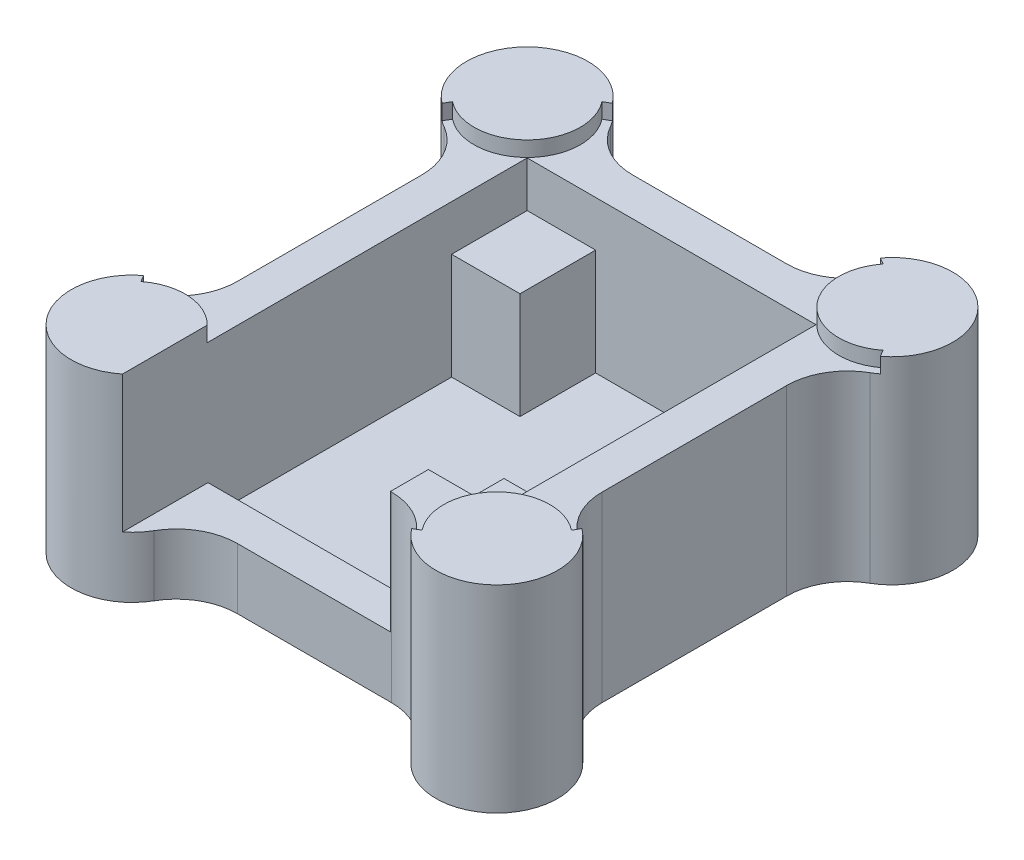
from build123d import *

# Parameters (mm, degrees)
BOSS_EXTRUDE1_DEPTH     = 12
CUT_EXTRUDE1_DEPTH      = 10
FILLET1_R               = 4
BOSS_EXTRUDE3_DEPTH     = 1
MIRROR2_COPY_1_DEPTH    = 1
SKETCH3_W               = 14.5
SKETCH3_H               = 5.622498999
CUT_EXTRUDE2_DEPTH      = 2
CUT_EXTRUDE2_DEPTH_BACK = 8
SKETCH4_W               = 4.5
SKETCH4_H               = 4.973684211
CUT_EXTRUDE3_DEPTH      = 3


with BuildPart() as part:
    # Sketch1 → Boss-Extrude1 (new body)
    with BuildSketch(Plane(origin=(0, 0, 0), x_dir=(1, 0, 0), z_dir=(0, 1, 0))):
        with BuildLine():
            Line((-8, -13), (8, -13))
            ThreePointArc((8, -13), (14.828427125, -15.828427125), (12, -9))
            Line((12, -9), (12, 9))
            ThreePointArc((12, 9), (14.828427125, 15.828427125), (8, 13))
            Line((8, 13), (-8, 13))
            ThreePointArc((-8, 13), (-14.828427125, 15.828427125), (-12, 9))
            Line((-12, 9), (-12, -9))
            ThreePointArc((-12, -9), (-14.828427125, -15.828427125), (-8, -13))
        make_face()
    extrude(amount=BOSS_EXTRUDE1_DEPTH)

    # Sketch2 → Cut-Extrude1 (cut)
    with BuildSketch(Plane(origin=(0, 12, 0), x_dir=(1, 0, 0), z_dir=(0, 1, 0))):
        Polygon((-9.5, -10.5), (5, -10.5), (5, -5.526315789), (9.5, -5.526315789), (9.5, 10.5), (-5, 10.5), (-5, 5.526315789), (-9.5, 5.526315789), align=None)
    extrude(amount=-CUT_EXTRUDE1_DEPTH, mode=Mode.SUBTRACT)

    # Fillet1
    fillet1_edges = [part.edges().sort_by_distance(p)[0] for p in [
        (12, 6, -9),
        (12, 6, 9),
        (8, 6, 13),
        (-8, 6, 13),
        (-12, 6, 9),
        (-12, 6, -9),
        (-8, 6, -13),
        (8, 6, -13),
    ]]
    fillet(fillet1_edges, radius=FILLET1_R)

    # Sketch10 → Boss-Extrude3 (add)
    with BuildSketch(Plane(origin=(0, 12, 0), x_dir=(1, 0, 0), z_dir=(0, 1, 0))):
        with BuildLine():
            Line((14.417326185, -9.813068229), (14.165063509, -10.25))
            ThreePointArc((14.165063509, -10.25), (9.525126266, -10.525126266), (9.25, -15.165063509))
            Line((9.25, -15.165063509), (8.813068229, -15.417326185))
            ThreePointArc((8.813068229, -15.417326185), (14.828427125, -15.828427125), (14.417326185, -9.813068229))
        make_face()
    boss_extrude3 = extrude(amount=BOSS_EXTRUDE3_DEPTH)

    # Mirror1: Boss-Extrude3 across plane
    add(boss_extrude3.mirror(Plane(origin=(0, 0, 0), x_dir=(0, 0, 1), z_dir=(1, 0, 0))))

    # Mirror2: Boss-Extrude3 across plane
    add(boss_extrude3.mirror(Plane.XY))

    # Mirror2 copy 1 sketch → Mirror2 copy 1 (add)
    with BuildSketch(Plane(origin=(0, 12, 0), x_dir=(-1, 0, 0), z_dir=(0, 1, 0))):
        with BuildLine():
            Line((14.417326185, -9.813068229), (14.165063509, -10.25))
            ThreePointArc((14.165063509, -10.25), (9.525126266, -10.525126266), (9.25, -15.165063509))
            Line((9.25, -15.165063509), (8.813068229, -15.417326185))
            ThreePointArc((8.813068229, -15.417326185), (14.828427125, -15.828427125), (14.417326185, -9.813068229))
        make_face()
    extrude(amount=MIRROR2_COPY_1_DEPTH)

    # Sketch3 → Cut-Extrude2 (cut, two sides)
    with BuildSketch(Plane(origin=(0, 12, 0), x_dir=(1, 0, 0), z_dir=(0, 1, 0))) as cut_extrude2_sk:
        with Locations((-2.25, -13.3112495)):
            Rectangle(SKETCH3_W, SKETCH3_H)
    extrude(amount=CUT_EXTRUDE2_DEPTH, mode=Mode.SUBTRACT)
    extrude(cut_extrude2_sk.sketch, amount=-CUT_EXTRUDE2_DEPTH_BACK, mode=Mode.SUBTRACT)

    # Sketch4 → Cut-Extrude3 (cut)
    with BuildSketch(Plane(origin=(0, 12, 0), x_dir=(1, 0, 0), z_dir=(0, 1, 0))):
        with Locations((-7.25, 8.013157895)):
            Rectangle(SKETCH4_W, SKETCH4_H)
        with Locations((7.25, -8.013157895)):
            Rectangle(SKETCH4_W, SKETCH4_H)
    extrude(amount=-CUT_EXTRUDE3_DEPTH, mode=Mode.SUBTRACT)


solid = part.part
